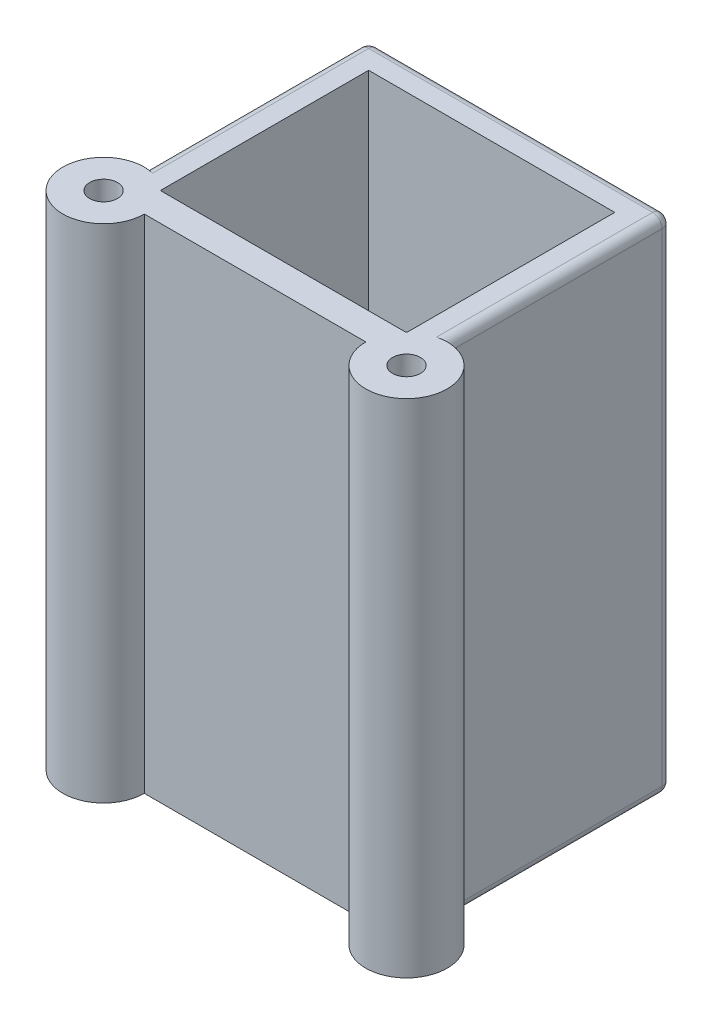
from build123d import *

# Parameters (mm, degrees)
SKETCH1_W           = 32
SKETCH1_H           = 28
BOSS_EXTRUDE1_DEPTH = 53
SKETCH2_W           = 26
SKETCH2_H           = 22
CUT_EXTRUDE1_DEPTH  = 56
SKETCH9_R           = 4.3
BOSS_EXTRUDE5_DEPTH = 53
SKETCH10_R          = 1.47
CUT_EXTRUDE5_DEPTH  = 53
SKETCH11_R          = 4.3
BOSS_EXTRUDE6_DEPTH = 53
SKETCH12_W          = 26
SKETCH12_H          = 3
BOSS_EXTRUDE7_DEPTH = 10
SKETCH13_R          = 1.47
CUT_EXTRUDE6_DEPTH  = 53
FILLET1_R           = 1


with BuildPart() as part:
    # Sketch1 → Boss-Extrude1 (new body)
    with BuildSketch(Plane(origin=(0, 0, 0), x_dir=(1, 0, 0), z_dir=(0, 1, 0))):
        with Locations((-16.792307692, 2.619230769)):
            Rectangle(SKETCH1_W, SKETCH1_H)
    extrude(amount=BOSS_EXTRUDE1_DEPTH)

    # Sketch2 → Cut-Extrude1 (cut)
    with BuildSketch(Plane(origin=(0, 53, 0), x_dir=(1, 0, 0), z_dir=(0, 1, 0))):
        with Locations((-16.792307692, 2.619230769)):
            Rectangle(SKETCH2_W, SKETCH2_H)
    extrude(amount=-CUT_EXTRUDE1_DEPTH, mode=Mode.SUBTRACT)

    # Sketch9 → Boss-Extrude5 (add)
    with BuildSketch(Plane(origin=(0, 53, 0), x_dir=(1, 0, 0), z_dir=(0, 1, 0))):
        with Locations((-32.792307692, -11.380769231)):
            Circle(SKETCH9_R)
    extrude(amount=-BOSS_EXTRUDE5_DEPTH)

    # Sketch10 → Cut-Extrude5 (cut)
    with BuildSketch(Plane(origin=(0, 53, 0), x_dir=(1, 0, 0), z_dir=(0, 1, 0))):
        with Locations((-32.792307692, -11.380769231)):
            Circle(SKETCH10_R)
    extrude(amount=-CUT_EXTRUDE5_DEPTH, mode=Mode.SUBTRACT)

    # Sketch11 → Boss-Extrude6 (add)
    with BuildSketch(Plane(origin=(0, 53, 0), x_dir=(1, 0, 0), z_dir=(0, 1, 0))):
        with Locations((-0.792307692, -11.380769231)):
            Circle(SKETCH11_R)
    extrude(amount=-BOSS_EXTRUDE6_DEPTH)

    # Sketch12 → Boss-Extrude7 (add)
    with BuildSketch(Plane.XY.offset(-13.619230769)):
        with Locations((-16.792307692, 1.5)):
            Rectangle(SKETCH12_W, SKETCH12_H)
    extrude(amount=BOSS_EXTRUDE7_DEPTH)

    # Sketch13 → Cut-Extrude6 (cut)
    with BuildSketch(Plane(origin=(0, 53, 0), x_dir=(1, 0, 0), z_dir=(0, 1, 0))):
        with Locations((-0.792307692, -11.380769231)):
            Circle(SKETCH13_R)
    extrude(amount=-CUT_EXTRUDE6_DEPTH, mode=Mode.SUBTRACT)

    # Fillet1
    fillet1_edges = [part.edges().sort_by_distance(p)[0] for p in [
        (-16.792307692, 53, -16.619230769),
        (-32.792307692, 53, -4.769230769),
        (-16.792307692, 0, -16.619230769),
        (-32.792307692, 0, -4.769230769),
        (-0.792307692, 0, -4.769230769),
        (-0.792307692, 53, -4.769230769),
        (-32.792307692, 26.5, -16.619230769),
        (-0.792307692, 26.5, -16.619230769),
    ]]
    fillet(fillet1_edges, radius=FILLET1_R)


solid = part.part
